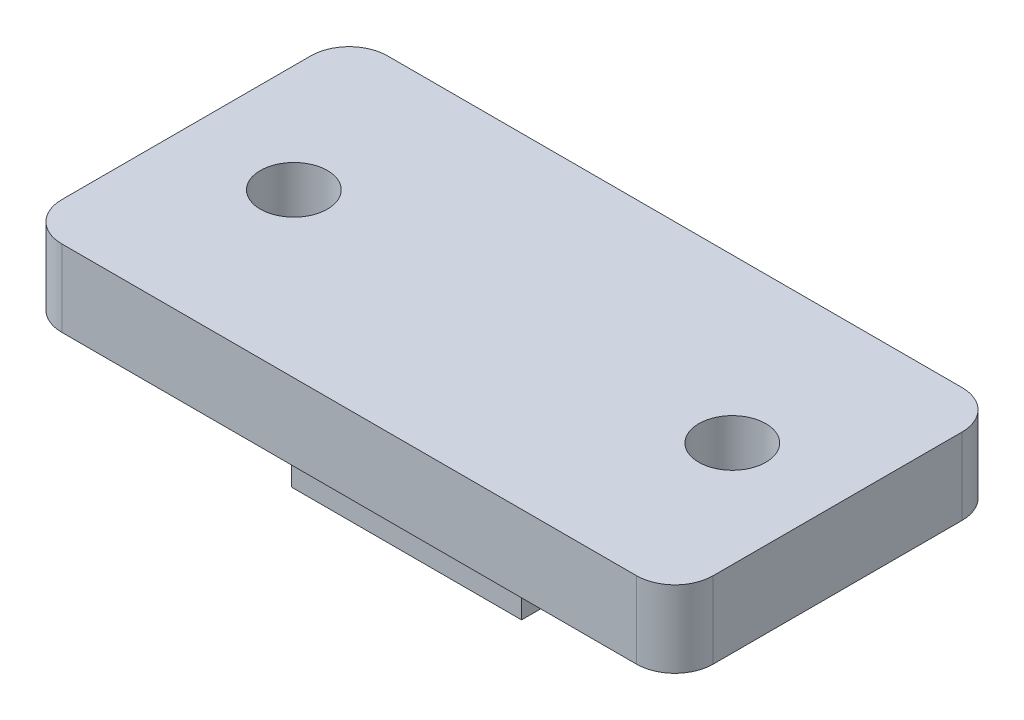
from build123d import *

# Parameters (mm, degrees)
SKETCH1_W           = 12
SKETCH1_H           = 11
BOSS_EXTRUDE1_DEPTH = 4
SKETCH2_W           = 34
SKETCH2_H           = 17
BOSS_EXTRUDE2_DEPTH = 4
SKETCH3_R           = 1.75
CUT_EXTRUDE1_DEPTH  = 5
FILLET1_R           = 2


with BuildPart() as part:
    # Sketch1 → Boss-Extrude1 (new body)
    with BuildSketch(Plane(origin=(0, 0, 0), x_dir=(1, 0, 0), z_dir=(0, 1, 0))):
        with Locations((6, -5.5)):
            Rectangle(SKETCH1_W, SKETCH1_H)
    extrude(amount=BOSS_EXTRUDE1_DEPTH)

    # Sketch2 → Boss-Extrude2 (add)
    with BuildSketch(Plane(origin=(0, 4, 0), x_dir=(1, 0, 0), z_dir=(0, 1, 0))):
        with Locations((6, -5.5)):
            Rectangle(SKETCH2_W, SKETCH2_H)
    extrude(amount=BOSS_EXTRUDE2_DEPTH)

    # Sketch3 → Cut-Extrude1 (cut, through all)
    with BuildSketch(Plane.XZ.offset(-4)):
        with Locations((-5.385399537, 5.5)):
            Circle(SKETCH3_R)
        with Locations((17.5, 5.5)):
            Circle(SKETCH3_R)
    extrude(amount=-CUT_EXTRUDE1_DEPTH, mode=Mode.SUBTRACT)

    # Fillet1
    fillet1_edges = [part.edges().sort_by_distance(p)[0] for p in [
        (23, 6, 14),
        (23, 6, -3),
        (-11, 6, -3),
        (-11, 6, 14),
    ]]
    fillet(fillet1_edges, radius=FILLET1_R)


solid = part.part
